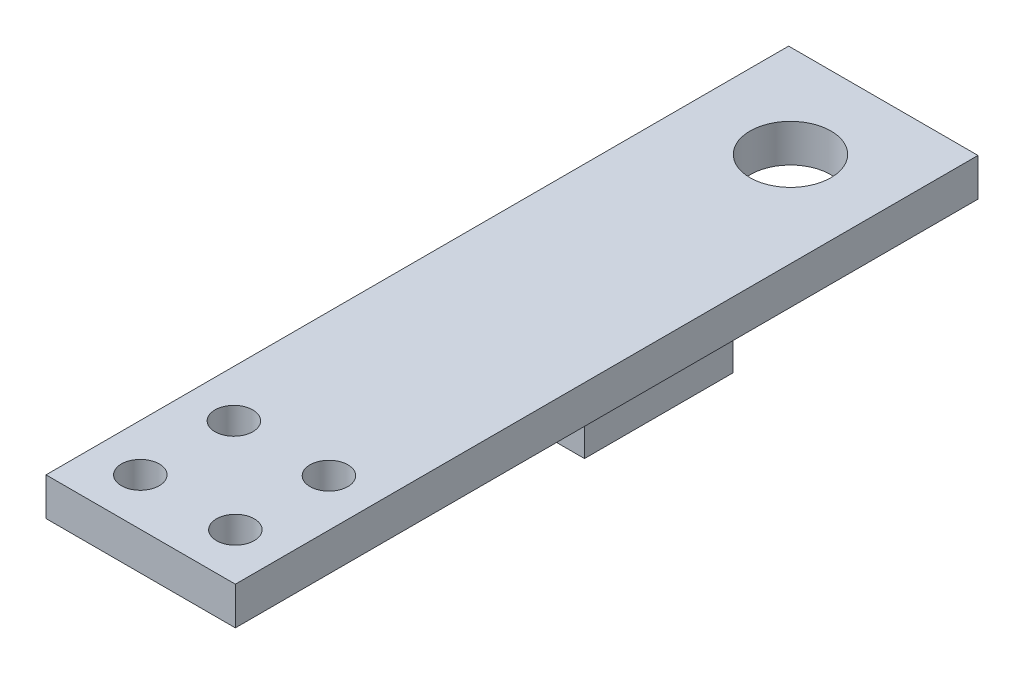
from build123d import *

# Parameters (mm, degrees)
SKETCH1_W    = 5.1
SKETCH1_H    = 20
SKETCH1_R    = 1.09
SKETCH1_R_2  = 0.51
SKETCH1_W_2  = 3.604970558
SKETCH1_H_2  = 4
BODY_DEPTH   = 1.02
SKETCH3_W    = 3.604970558
SKETCH3_H    = 4
SENSOR_DEPTH = 2.52


with BuildPart() as part:
    # Sketch1 → Body (new body)
    with BuildSketch(Plane(origin=(0, 0, 0), x_dir=(1, 0, 0), z_dir=(0, 1, 0))):
        Rectangle(SKETCH1_W, SKETCH1_H)
        with Locations((0, 7.5)):
            Circle(SKETCH1_R, mode=Mode.SUBTRACT)
        with Locations((-1.28, -6.21)):
            Circle(SKETCH1_R_2, mode=Mode.SUBTRACT)
        with Locations((-1.28, -8.73)):
            Circle(SKETCH1_R_2, mode=Mode.SUBTRACT)
        with Locations((1.28, -6.21)):
            Circle(SKETCH1_R_2, mode=Mode.SUBTRACT)
        with Locations((1.28, -8.73)):
            Circle(SKETCH1_R_2, mode=Mode.SUBTRACT)
        with Locations((0, 2.15)):
            Rectangle(SKETCH1_W_2, SKETCH1_H_2, mode=Mode.SUBTRACT)
    extrude(amount=BODY_DEPTH)

    # Sketch3 → Sensor (add)
    with BuildSketch(Plane(origin=(0, 1.02, 0), x_dir=(1, 0, 0), z_dir=(0, 1, 0))):
        with Locations((0, 2.15)):
            Rectangle(SKETCH3_W, SKETCH3_H)
    extrude(amount=-SENSOR_DEPTH)


solid = part.part
